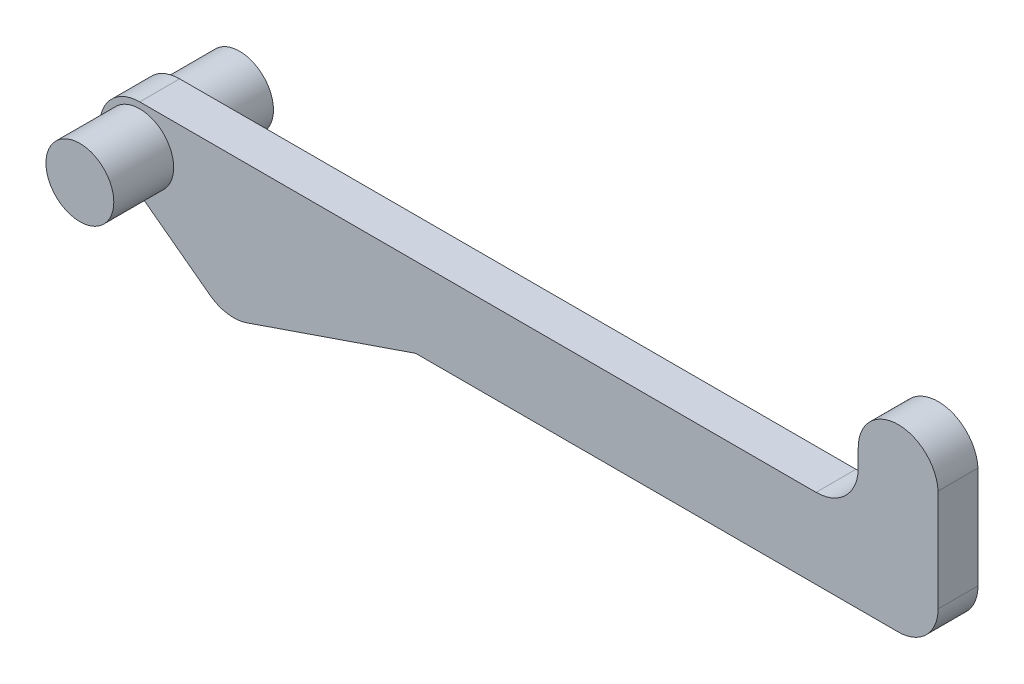
from build123d import *

# Parameters (mm, degrees)
BOSS_EXTRU_1_DEPTH      = 10
ESQUISSE2_R             = 8.5
BOSS_EXTRU_2_DEPTH      = 15
BOSS_EXTRU_2_DEPTH_BACK = 25


with BuildPart() as part:
    # Esquisse1 → Boss.-Extru.1 (new body)
    with BuildSketch(Plane.XY):
        with BuildLine():
            Line((-38.999653337, 10.226454502), (-81.337427048, -4.313992939))
            ThreePointArc((-81.337427048, -4.313992939), (-86.130996021, -4.736088564), (-90.566704705, -2.870356351))
            Line((-90.566704705, -2.870356351), (-108.115218138, 10.226454502))
            ThreePointArc((-108.115218138, 10.226454502), (-118.115218138, 20.226454502), (-108.115218138, 30.226454502))
            Line((-108.115218138, 30.226454502), (61.31386316, 30.226454502))
            ThreePointArc((61.31386316, 30.226454502), (68.788631458, 33.322604906), (71.884781862, 40.797373204))
            Line((71.884781862, 40.797373204), (71.884781862, 45.226454502))
            ThreePointArc((71.884781862, 45.226454502), (81.607354933, 55.230528024), (91.884781862, 45.797373204))
            Line((91.884781862, 45.797373204), (91.884781862, 20.226454502))
            ThreePointArc((91.884781862, 20.226454502), (88.955849674, 13.15538669), (81.884781862, 10.226454502))
            Line((81.884781862, 10.226454502), (-38.999653337, 10.226454502))
        make_face()
    extrude(amount=BOSS_EXTRU_1_DEPTH)

    # Esquisse2 → Boss.-Extru.2 (add, two sides)
    with BuildSketch(Plane.XY.offset(10)) as boss_extru_2_sk:
        with Locations((-108.115218138, 20.226454502)):
            Circle(ESQUISSE2_R)
    extrude(amount=BOSS_EXTRU_2_DEPTH)
    extrude(boss_extru_2_sk.sketch, amount=-BOSS_EXTRU_2_DEPTH_BACK)


solid = part.part
